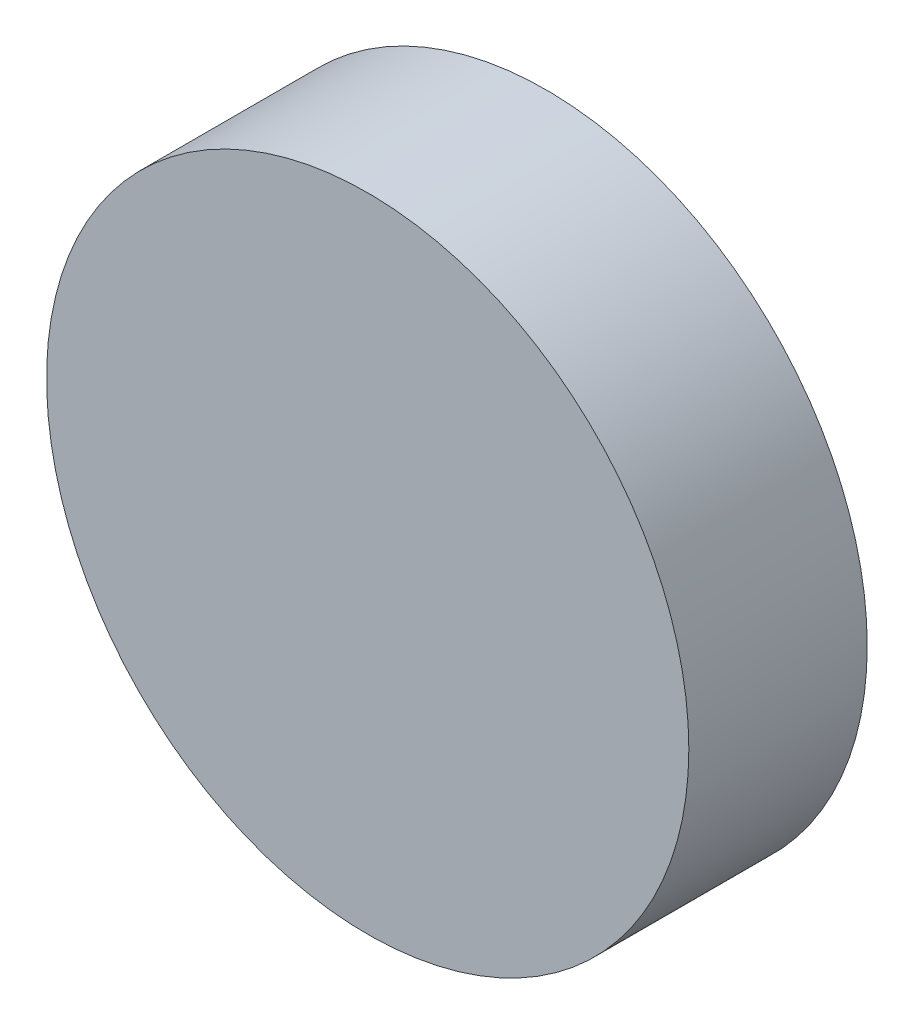
from build123d import *

# Parameters (mm, degrees)
SKETCH1_R           = 228.6
BOSS_EXTRUDE1_DEPTH = 127


with BuildPart() as part:
    # Sketch1 → Boss-Extrude1 (new body)
    with BuildSketch(Plane.XY):
        Circle(SKETCH1_R)
    extrude(amount=BOSS_EXTRUDE1_DEPTH)


solid = part.part
